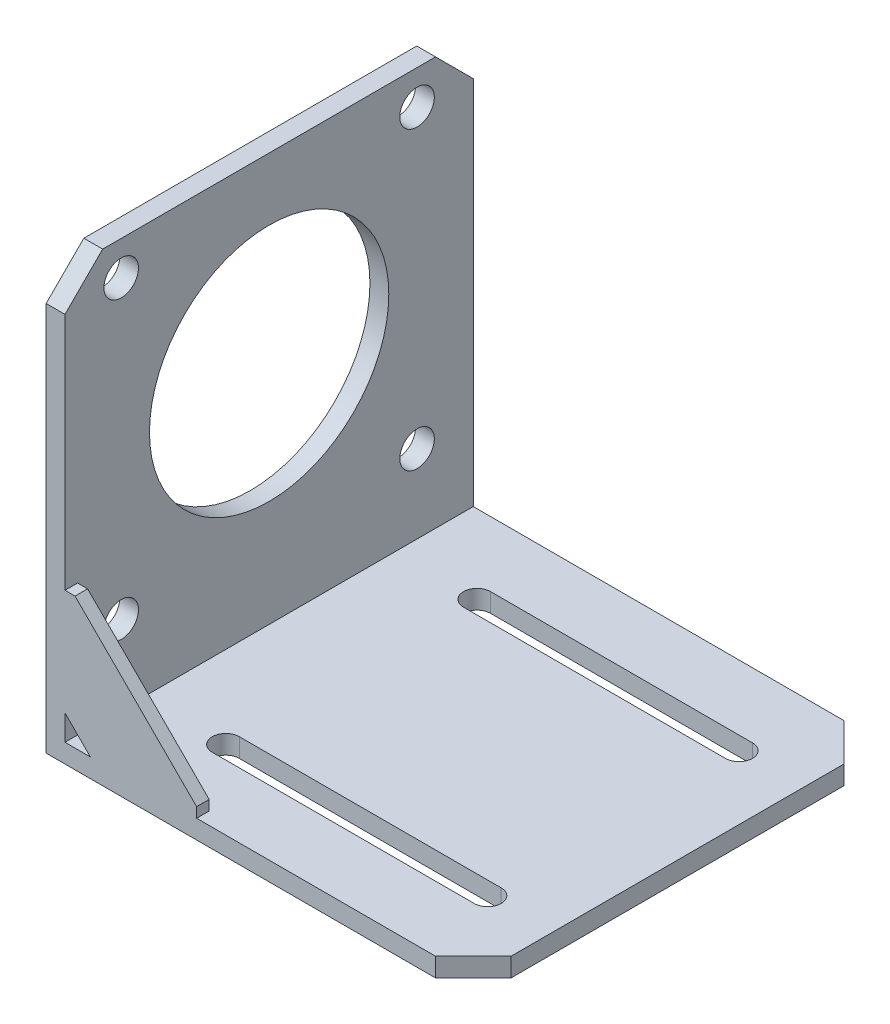
from build123d import *

# Parameters (mm, degrees)
BOSS_EXTRUDE1_DEPTH = 65
CHAMFER1_SIZE       = 6
BOSS_EXTRUDE2_DEPTH = 2
SKETCH3_R           = 19.05
SKETCH3_R_2         = 2.75
CUT_EXTRUDE1_DEPTH  = 3
CUT_EXTRUDE2_DEPTH  = 3


with BuildPart() as part:
    # Sketch1 → Boss-Extrude1 (new body)
    with BuildSketch(Plane.XY):
        Polygon((0, 0), (0, 68), (3, 68), (3, 3), (68, 3), (68, 0), align=None)
    extrude(amount=BOSS_EXTRUDE1_DEPTH)

    # Chamfer1
    chamfer1_edges = [part.edges().sort_by_distance(p)[0] for p in [
        (1.5, 68, 65),
        (1.5, 68, 0),
        (68, 1.5, 65),
        (68, 1.5, 0),
    ]]
    chamfer(chamfer1_edges, length=CHAMFER1_SIZE)

    # Sketch2 → Boss-Extrude2 (add)
    with BuildSketch(Plane.XY.offset(65)):
        Polygon((4.600185007, 23.955878092), (23.955878092, 4.600185007), (23.955878092, 3), (7.047822016, 3), (3, 7.047822016), (3, 23.955878092), align=None)
    extrude(amount=-BOSS_EXTRUDE2_DEPTH)

    # Sketch3 → Cut-Extrude1 (cut)
    with BuildSketch(Plane.ZY):
        with Locations((32.5, 39)):
            Circle(SKETCH3_R)
        with Locations((8.95, 62.55)):
            Circle(SKETCH3_R_2)
        with Locations((56.05, 62.55)):
            Circle(SKETCH3_R_2)
        with Locations((8.95, 15.45)):
            Circle(SKETCH3_R_2)
        with Locations((56.05, 15.45)):
            Circle(SKETCH3_R_2)
    extrude(amount=-CUT_EXTRUDE1_DEPTH, mode=Mode.SUBTRACT)

    # Sketch4 → Cut-Extrude2 (cut)
    with BuildSketch(Plane.XZ):
        with BuildLine():
            Line((16.1, 54.65), (57.8, 54.65))
            ThreePointArc((57.8, 54.65), (59.95, 52.5), (57.8, 50.35))
            Line((57.8, 50.35), (16.1, 50.35))
            ThreePointArc((16.1, 50.35), (13.95, 52.5), (16.1, 54.65))
        make_face()
        with BuildLine():
            Line((16.1, 14.65), (57.8, 14.65))
            ThreePointArc((57.8, 14.65), (59.95, 12.5), (57.8, 10.35))
            Line((57.8, 10.35), (16.1, 10.35))
            ThreePointArc((16.1, 10.35), (13.95, 12.5), (16.1, 14.65))
        make_face()
    extrude(amount=-CUT_EXTRUDE2_DEPTH, mode=Mode.SUBTRACT)


solid = part.part
